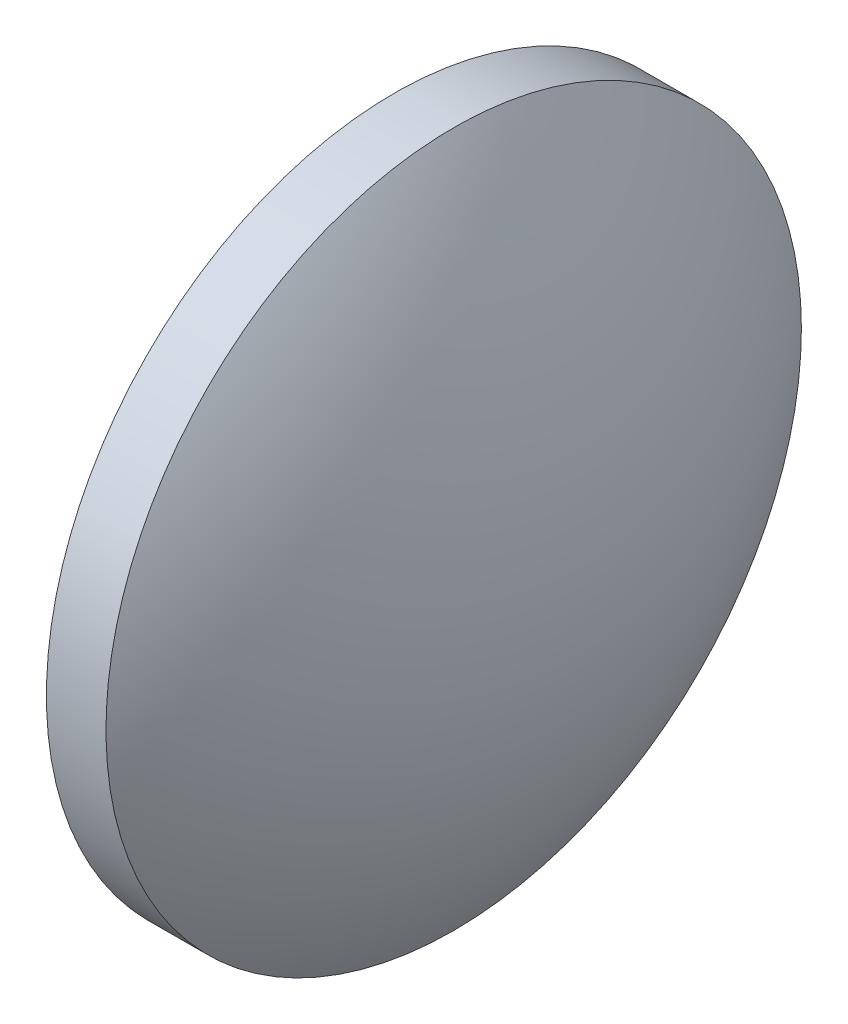
from build123d import *


with BuildPart() as part:
    # 草图1 → 旋转1 (revolve)
    with BuildSketch(Plane.XY, mode=Mode.PRIVATE) as revolve_1_sk:
        with BuildLine():
            Line((115.773606431, 65.233554926), (115.773606431, 77.933554926))
            Line((115.773606431, 77.933554926), (117.949372387, 77.933554926))
            ThreePointArc((117.949372387, 77.933554926), (120.796805756, 71.865198124), (121.773606431, 65.233554926))
            Line((121.773606431, 65.233554926), (115.773606431, 65.233554926))
        make_face()
    revolve(revolve_1_sk.sketch.rotate(Axis((121.773606431, 65.233554926, 0), (-1, 0, 0)), 180), axis=Axis((121.773606431, 65.233554926, 0), (-1, 0, 0)))  # turned: the seam where the file's is


solid = part.part
